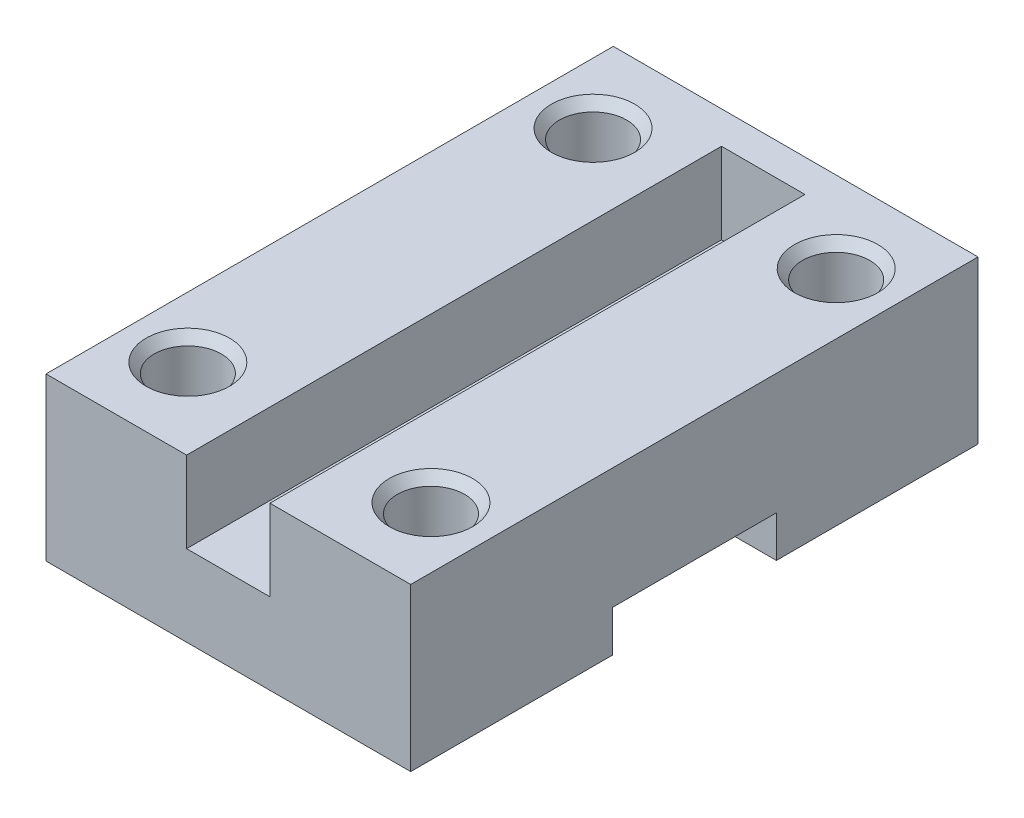
from build123d import *

# Parameters (mm, degrees)
SKETCH1_W               = 45
SKETCH1_H               = 70
BOSS_EXTRUDE1_DEPTH     = 10
SKETCH2_W               = 20.25
SKETCH2_H               = 5.1
CUT_EXTRUDE1_DEPTH      = 1
CUT_EXTRUDE1_DEPTH_BACK = 46
SKETCH3_R               = 4.15
CUT_EXTRUDE2_DEPTH      = 11
SKETCH5_R               = 4.15
BOSS_EXTRUDE2_DEPTH     = 10
CHAMFER1_SIZE           = 1
CHAMFER1_SIZE2          = 1.191753593


with BuildPart() as part:
    # Sketch1 → Boss-Extrude1 (new body)
    with BuildSketch(Plane(origin=(0, 0, 0), x_dir=(1, 0, 0), z_dir=(0, 1, 0))):
        Rectangle(SKETCH1_W, SKETCH1_H)
    extrude(amount=BOSS_EXTRUDE1_DEPTH)

    # Sketch2 → Cut-Extrude1 (cut, two sides)
    with BuildSketch(Plane(origin=(22.5, 0, 0), x_dir=(0, 0, -1), z_dir=(1, 0, 0))) as cut_extrude1_sk:
        with Locations((0, 2.55)):
            Rectangle(SKETCH2_W, SKETCH2_H)
    extrude(amount=CUT_EXTRUDE1_DEPTH, mode=Mode.SUBTRACT)
    extrude(cut_extrude1_sk.sketch, amount=-CUT_EXTRUDE1_DEPTH_BACK, mode=Mode.SUBTRACT)

    # Sketch3 → Cut-Extrude2 (cut, through all)
    with BuildSketch(Plane.XZ):
        with Locations((15, 25)):
            Circle(SKETCH3_R)
        with Locations((15, -25)):
            Circle(SKETCH3_R)
        with Locations((-15, -25)):
            Circle(SKETCH3_R)
        with Locations((-15, 25)):
            Circle(SKETCH3_R)
    extrude(amount=-CUT_EXTRUDE2_DEPTH, mode=Mode.SUBTRACT)

    # Sketch5 → Boss-Extrude2 (add)
    with BuildSketch(Plane(origin=(0, 10, 0), x_dir=(1, 0, 0), z_dir=(0, 1, 0))):
        Polygon((-5.15, -35), (-22.5, -35), (-22.5, 35), (22.5, 35), (22.5, -35), (5.15, -35), (5.130229348, -34.949305848), (5.15, 31), (-5.15, 31), align=None)
        with Locations((-15, 25)):
            Circle(SKETCH5_R, mode=Mode.SUBTRACT)
        with Locations((15, 25)):
            Circle(SKETCH5_R, mode=Mode.SUBTRACT)
        with Locations((15, -25)):
            Circle(SKETCH5_R, mode=Mode.SUBTRACT)
        with Locations((-15, -25)):
            Circle(SKETCH5_R, mode=Mode.SUBTRACT)
    extrude(amount=BOSS_EXTRUDE2_DEPTH)

    # Chamfer1
    chamfer1_edges = [part.edges().sort_by_distance(p)[0] for p in [
        (-19.15, 20, -25),
        (10.85, 20, -25),
        (10.85, 20, 25),
        (-19.15, 20, 25),
    ]]
    chamfer1_side = [part.faces().sort_by_distance(p)[0] for p in [
        (-13.825, 20, 34.167834151),
    ]]
    chamfer(chamfer1_edges, length=CHAMFER1_SIZE, length2=CHAMFER1_SIZE2, reference=chamfer1_side[0])


solid = part.part
